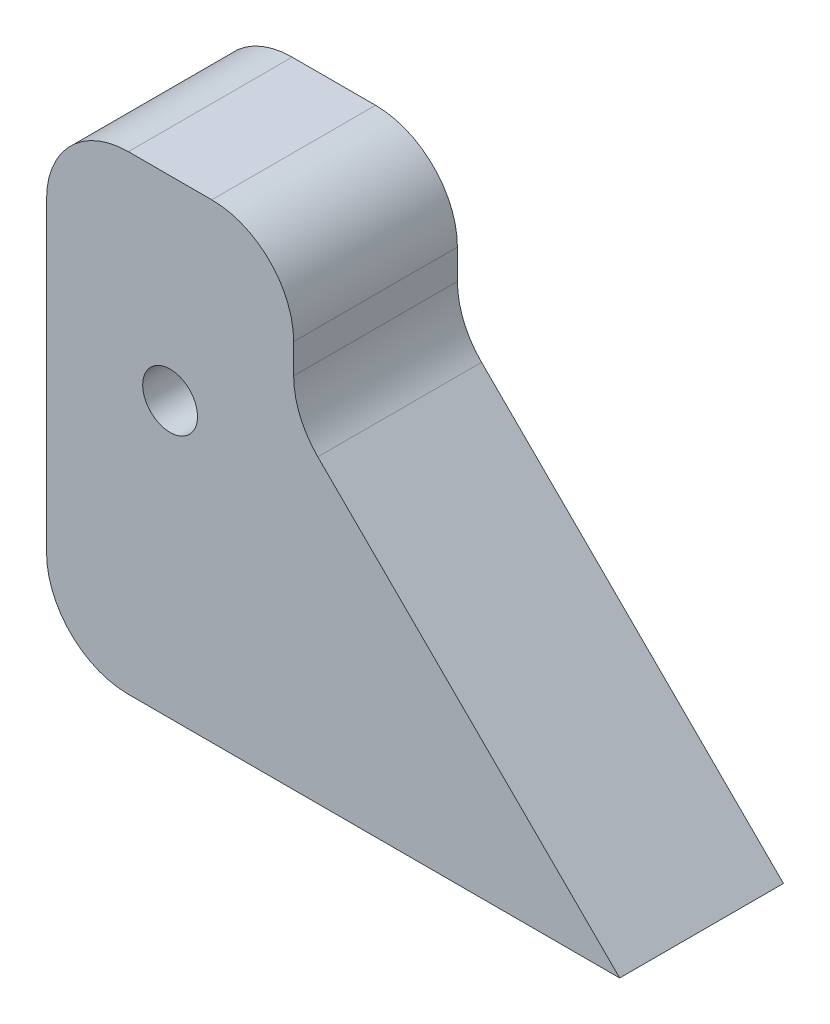
from build123d import *

# Parameters (mm, degrees)
BOSS_EXTRUDE1_DEPTH = 10
FILLET1_R           = 5
SKETCH2_R           = 3.2
CUT_EXTRUDE1_DEPTH  = 4.7
SKETCH3_R           = 1.6
CUT_EXTRUDE2_DEPTH  = 10
SKETCH5_R           = 3.2
CUT_EXTRUDE3_DEPTH  = 4.7
SKETCH6_R           = 3.2
BOSS_EXTRUDE2_DEPTH = 4.7
SKETCH8_R           = 1.675
CUT_EXTRUDE4_DEPTH  = 10


with BuildPart() as part:
    # Sketch1 → Boss-Extrude1 (new body)
    with BuildSketch(Plane.XY):
        Polygon((0, 0), (35, 0), (15.09, 19.81), (15.09, 28.7), (0, 28.7), align=None)
    extrude(amount=BOSS_EXTRUDE1_DEPTH)

    # Fillet1
    fillet1_edges = [part.edges().sort_by_distance(p)[0] for p in [
        (0, 28.7, 5),
        (15.09, 28.7, 5),
        (15.09, 19.81, 5),
        (0, 0, 5),
    ]]
    fillet(fillet1_edges, radius=FILLET1_R)

    # Sketch2 → Cut-Extrude1 (cut)
    with BuildSketch(Plane.XY.offset(10)):
        with Locations((7.545, 16.8)):
            Circle(SKETCH2_R)
    extrude(amount=-CUT_EXTRUDE1_DEPTH, mode=Mode.SUBTRACT)

    # Sketch3 → Cut-Extrude2 (cut)
    with BuildSketch(Plane.XY.offset(10)):
        with Locations((7.545, 16.8)):
            Circle(SKETCH3_R)
    extrude(amount=-CUT_EXTRUDE2_DEPTH, mode=Mode.SUBTRACT)

    # Sketch5 → Cut-Extrude3 (cut)
    with BuildSketch(Plane(origin=(0, 0, 0), x_dir=(-1, 0, 0), z_dir=(0, 0, -1))):
        with Locations((-7.545, 16.8)):
            Circle(SKETCH5_R)
    extrude(amount=-CUT_EXTRUDE3_DEPTH, mode=Mode.SUBTRACT)

    # Sketch6 → Boss-Extrude2 (add)
    with BuildSketch(Plane.XY.offset(10)):
        with Locations((7.545, 16.8)):
            Circle(SKETCH6_R)
    extrude(amount=-BOSS_EXTRUDE2_DEPTH)

    # Sketch8 → Cut-Extrude4 (cut)
    with BuildSketch(Plane(origin=(0, 0, 0), x_dir=(-1, 0, 0), z_dir=(0, 0, -1))):
        with Locations((-7.545, 16.8)):
            Circle(SKETCH8_R)
    extrude(amount=-CUT_EXTRUDE4_DEPTH, mode=Mode.SUBTRACT)


solid = part.part
